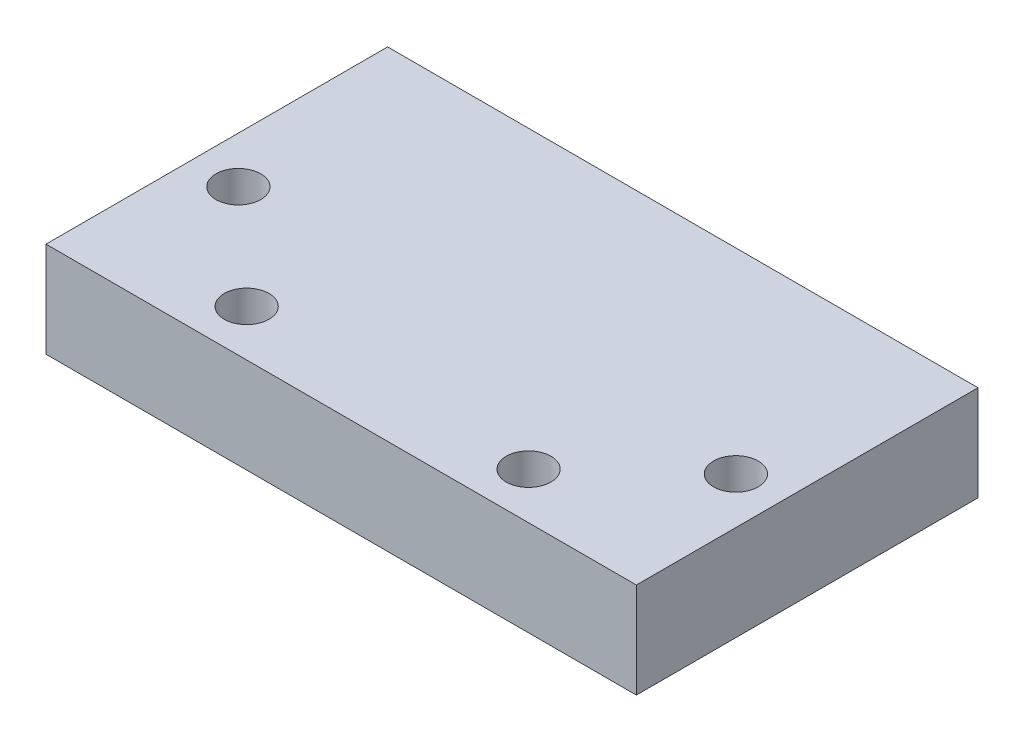
from build123d import *

# Parameters (mm, degrees)
BOSS_EXTRUDE1_DEPTH = 7.5
SKETCH8_W           = 35.6
SKETCH8_H           = 5.75
BOSS_EXTRUDE4_DEPTH = 5.6
SKETCH9_R           = 1.35
CUT_EXTRUDE3_DEPTH  = 6.75


with BuildPart() as part:
    # Sketch1 → Boss-Extrude1 (new body, symmetric)
    with BuildSketch(Plane.XY):
        Polygon((-17.8, 5.75), (17.8, 5.75), (17.8, 0), (12.2, 0), (12.2, 2.75), (-12.2, 2.75), (-12.2, 0), (-17.8, 0), align=None)
    extrude(amount=BOSS_EXTRUDE1_DEPTH, both=True)

    # Sketch8 → Boss-Extrude4 (add)
    with BuildSketch(Plane.XY.offset(7.5)):
        with Locations((0, 2.875)):
            Rectangle(SKETCH8_W, SKETCH8_H)
    extrude(amount=BOSS_EXTRUDE4_DEPTH)

    # Sketch9 → Cut-Extrude3 (cut, through all)
    with BuildSketch(Plane(origin=(0, 5.75, 0), x_dir=(1, 0, 0), z_dir=(0, 1, 0))):
        with Locations((-8.5, -10.3)):
            Circle(SKETCH9_R)
        with Locations((-15, -4.3)):
            Circle(SKETCH9_R)
        with Locations((8.5, -10.3)):
            Circle(SKETCH9_R)
        with Locations((15, -4.3)):
            Circle(SKETCH9_R)
    extrude(amount=-CUT_EXTRUDE3_DEPTH, mode=Mode.SUBTRACT)


solid = part.part
